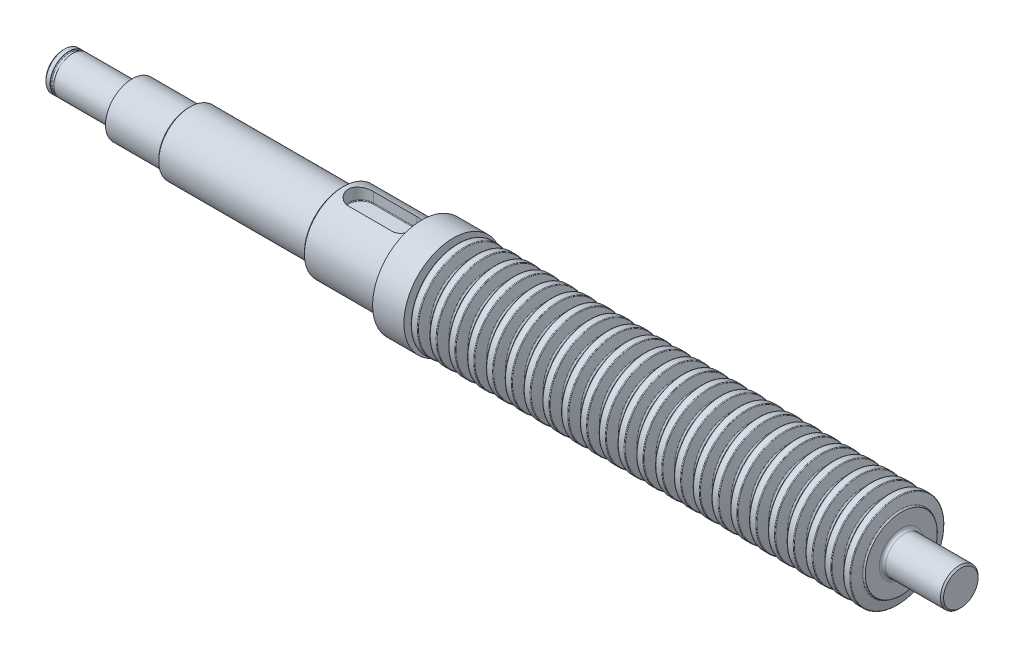
from build123d import *

# Parameters (mm, degrees)
PATTERN_LINEAR_1_COUNT      = 24
PATTERN_LINEAR_1_PITCH      = 6
FILLET_3_R                  = 1
CHAMFER_1_SIZE              = 0.5
FILLET_6_R                  = 0.5
CUT_EXTRUDE_3062_REACH      = 178.979
CUT_EXTRUDE_3062_END_RADIUS = 12.5
CUT_EXTRUDE_START           = 8.5
FILLET_5_R                  = 0.2


with BuildPart() as part:
    # Эскиз1 → Повернуть1 (revolve)
    with BuildSketch(Plane.XY):
        Polygon((-119.5, 0), (-119.5, 6), (-97.5, 6), (-97.5, 8.5), (-79.5, 8.5), (-79.5, 10.00005), (-30.5, 10.00005), (-30.5, 12.5), (-5, 12.5), (-5, 15.75), (5, 15.75), (5, 11.5), (148, 11.5), (148, 6), (167, 6), (167, 0), align=None)
    revolve(axis=Axis((167, 0, 0), (1, 0, 0)))

    # Эскиз2<2> → Повернуть2 (revolve)
    with BuildSketch(Plane.XY):
        with BuildLine():
            Line((6.673755536, 15), (8.486244464, 15))
            ThreePointArc((8.486244464, 15), (8.638434822, 14.948338335), (8.727725921, 14.814704761))
            Line((8.727725921, 14.814704761), (9.516598966, 11.870590477))
            ThreePointArc((9.516598966, 11.870590477), (9.695181164, 11.60332333), (9.999561879, 11.5))
            Line((9.999561879, 11.5), (5.160438121, 11.5))
            ThreePointArc((5.160438121, 11.5), (5.464818836, 11.60332333), (5.643401034, 11.870590477))
            Line((5.643401034, 11.870590477), (6.432274079, 14.814704761))
            ThreePointArc((6.432274079, 14.814704761), (6.521565178, 14.948338335), (6.673755536, 15))
        make_face()
    revolve_2 = revolve(axis=Axis((0, 0, 0), (1, 0, 0)))

    # Линейный массив1: Повернуть2 ×24
    with Locations(*[(i * PATTERN_LINEAR_1_PITCH, 0, 0) for i in range(1, PATTERN_LINEAR_1_COUNT)]):
        add(revolve_2)

    # Скругление3
    fillet_3_edges = [part.edges().sort_by_distance(p)[0] for p in [
        (148, -6, 0),
        (-5, -12.5, 0),
        (-30.5, -10.00005, 0),
        (-97.5, -6, 0),
    ]]
    fillet(fillet_3_edges, radius=FILLET_3_R)

    # Фаска1
    chamfer_1_edges = [part.edges().sort_by_distance(p)[0] for p in [
        (-119.5, -6, 0),
        (167, -6, 0),
        (-79.5, -10.00005, 0),
        (-30.5, -12.5, 0),
    ]]
    chamfer(chamfer_1_edges, length=CHAMFER_1_SIZE)

    # Скругление6
    fillet_6_edges = [part.edges().sort_by_distance(p)[0] for p in [
        (-79.5, -8.5, 0),
    ]]
    fillet(fillet_6_edges, radius=FILLET_6_R)

    # Эскиз6 → Канавка для DIN 6799 - 10, Замковое кольцо для вала1 (revolve, cut)
    with BuildSketch(Plane(origin=(167.5, 0, 0), x_dir=(0, 0, 1), z_dir=(0, -1, 0))):
        with BuildLine():
            Line((5.9, 284), (7, 284))
            Line((7, 284), (7, 285.2))
            Line((7, 285.2), (5.9, 285.2))
            ThreePointArc((5.9, 285.2), (5.723223305, 285.126776695), (5.65, 284.95))
            Line((5.65, 284.95), (5.65, 284.25))
            ThreePointArc((5.65, 284.25), (5.723223305, 284.073223305), (5.9, 284))
        make_face()
    revolve(axis=Axis((167, 0, 0), (-1, 0, 0)), mode=Mode.SUBTRACT)

    # Cut-Extrude 3062: up to this cylinder (the profile starts inside it)
    cut_extrude_3062_end = Plane(origin=(-17.5, 0, 0), z_dir=(-1, 0, 0)) * Cylinder(CUT_EXTRUDE_3062_END_RADIUS, 383.958, mode=Mode.PRIVATE)
    # Эскиз7 → Cut-Extrude 3062 (cut, up to the surface)
    with BuildSketch(Plane(origin=(0, 0, 0), x_dir=(1, 0, 0), z_dir=(0, 1, 0)).offset(CUT_EXTRUDE_START), mode=Mode.PRIVATE) as cut_extrude_3062_sk1:
        with BuildLine():
            Line((-24.5, -4), (-10.5, -4))
            ThreePointArc((-10.5, -4), (-6.5, 0), (-10.5, 4))
            Line((-10.5, 4), (-24.5, 4))
            ThreePointArc((-24.5, 4), (-28.5, 0), (-24.5, -4))
        make_face()
    cut_extrude_3062_tool1 = extrude(cut_extrude_3062_sk1.sketch, amount=CUT_EXTRUDE_3062_REACH, mode=Mode.PRIVATE) & cut_extrude_3062_end
    add(cut_extrude_3062_tool1.solids().sort_by_distance((-17.5, 8.5, 0))[0], mode=Mode.SUBTRACT)

    # Скругление5
    fillet_5_edges = [part.edges().sort_by_distance(p)[0] for p in [
        (-6.5, 8.5, 0),
        (-17.5, 8.5, 4),
        (-28.5, 8.5, 0),
        (-17.5, 8.5, -4),
    ]]
    fillet(fillet_5_edges, radius=FILLET_5_R)


solid = part.part
